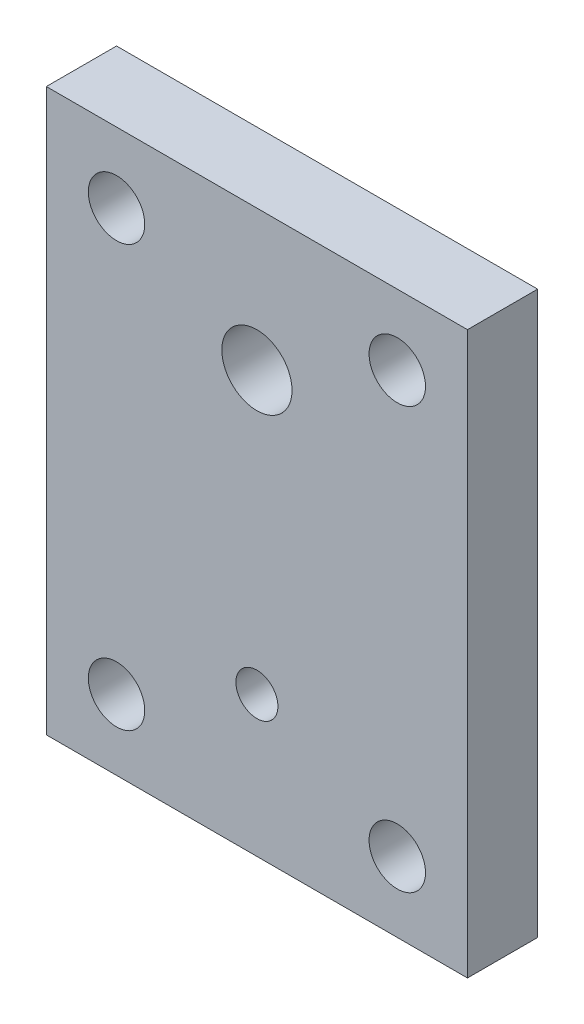
from build123d import *

# Parameters (mm, degrees)
SKETCH3_W           = 38.1
SKETCH3_H           = 50.8
SKETCH3_R           = 2.5527
SKETCH3_R_2         = 3.175
SKETCH3_R_3         = 1.89865
BOSS_EXTRUDE4_DEPTH = 6.35


with BuildPart() as part:
    # Sketch3 → Boss-Extrude4 (new body)
    with BuildSketch(Plane.XY):
        with Locations((19.05, 25.4)):
            Rectangle(SKETCH3_W, SKETCH3_H)
        with Locations((6.35, 44.45)):
            Circle(SKETCH3_R, mode=Mode.SUBTRACT)
        with Locations((31.75, 44.45)):
            Circle(SKETCH3_R, mode=Mode.SUBTRACT)
        with Locations((31.75, 6.35)):
            Circle(SKETCH3_R, mode=Mode.SUBTRACT)
        with Locations((6.35, 6.35)):
            Circle(SKETCH3_R, mode=Mode.SUBTRACT)
        with Locations((19.05, 38.1)):
            Circle(SKETCH3_R_2, mode=Mode.SUBTRACT)
        with Locations((19.05, 12.7)):
            Circle(SKETCH3_R_3, mode=Mode.SUBTRACT)
    extrude(amount=BOSS_EXTRUDE4_DEPTH)


solid = part.part
